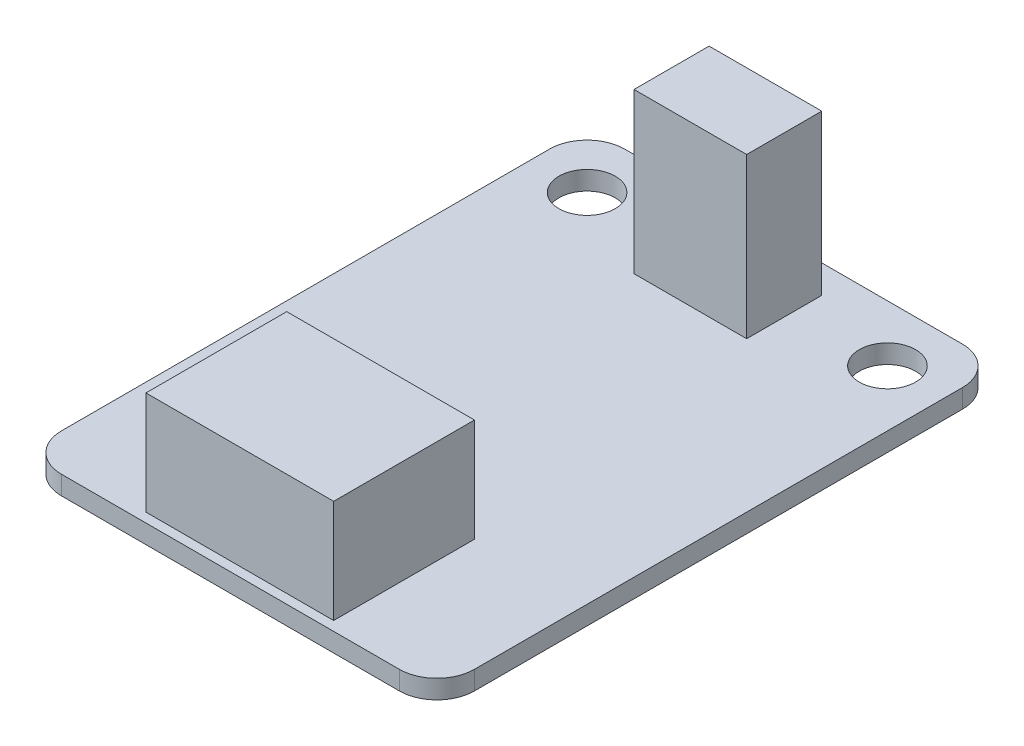
from build123d import *

# Parameters (mm, degrees)
BOSS_EXTRU_1_DEPTH      = 1
ESQUISSE3_R             = 1.5
ENL_V_MAT_EXTRU_1_DEPTH = 1
ESQUISSE4_W             = 6
ESQUISSE4_H             = 4
BOSS_EXTRU_2_DEPTH      = 8.5
ESQUISSE7_W             = 10
ESQUISSE7_H             = 7.5
BOSS_EXTRU_4_DEPTH      = 5.5


with BuildPart() as part:
    # Esquisse1 → Boss.-Extru.1 (new body)
    with BuildSketch(Plane(origin=(0, 0, 0), x_dir=(1, 0, 0), z_dir=(0, 1, 0))):
        with BuildLine():
            Line((2, 0), (20, 0))
            ThreePointArc((20, 0), (21.414213562, 0.585786438), (22, 2))
            Line((22, 2), (22, 28))
            ThreePointArc((22, 28), (21.414213562, 29.414213562), (20, 30))
            Line((20, 30), (2, 30))
            ThreePointArc((2, 30), (0.585786438, 29.414213562), (0, 28))
            Line((0, 28), (0, 2))
            ThreePointArc((0, 2), (0.585786438, 0.585786438), (2, 0))
        make_face()
    extrude(amount=BOSS_EXTRU_1_DEPTH)

    # Esquisse3 → Enlèv. mat.-Extru.1 (cut)
    with BuildSketch(Plane(origin=(0, 1, 0), x_dir=(1, 0, 0), z_dir=(0, 1, 0))):
        with Locations((3, 27)):
            Circle(ESQUISSE3_R)
        with Locations((19, 27)):
            Circle(ESQUISSE3_R)
    extrude(amount=-ENL_V_MAT_EXTRU_1_DEPTH, mode=Mode.SUBTRACT)

    # Esquisse4 → Boss.-Extru.2 (add)
    with BuildSketch(Plane(origin=(0, 1, 0), x_dir=(1, 0, 0), z_dir=(0, 1, 0))):
        with Locations((11, 26.5)):
            Rectangle(ESQUISSE4_W, ESQUISSE4_H)
    extrude(amount=BOSS_EXTRU_2_DEPTH)

    # Esquisse6 → Révolution1 (revolve)
    with BuildSketch(Plane(origin=(11, 0, 0), x_dir=(0, 0, -1), z_dir=(1, 0, 0))):
        with BuildLine():
            Line((28.5, 6.5), (30, 6.5))
            ThreePointArc((30, 6.5), (29.596229956, 5.042262026), (28.5, 4))
            Line((28.5, 4), (28.5, 6.5))
        make_face()
    revolve(axis=Axis((11, 6.5, -28.5), (0, 0, -1)))

    # Esquisse7 → Boss.-Extru.4 (add)
    with BuildSketch(Plane(origin=(0, 1, 0), x_dir=(1, 0, 0), z_dir=(0, 1, 0))):
        with Locations((11, 4.25)):
            Rectangle(ESQUISSE7_W, ESQUISSE7_H)
    extrude(amount=BOSS_EXTRU_4_DEPTH)


solid = part.part
